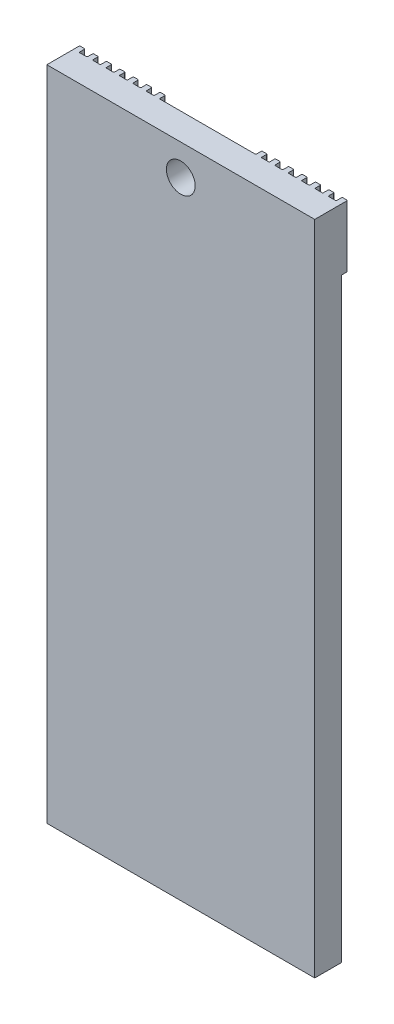
from build123d import *

# Parameters (mm, degrees)
RESSALTO_EXTRUS_O2_DEPTH = 9.2
ESBO_O5_R                = 2.15
CORTE_EXTRUS_O2_DEPTH    = 9.2
CHANFRO2_SIZE            = 0.3
SKETCH1_W                = 40
SKETCH1_H                = 3.972261678
BOSS_EXTRUDE1_DEPTH      = 88.9


with BuildPart() as part:
    # Esboço4 → Ressalto-extrusão2 (new body)
    with BuildSketch(Plane(origin=(0, 0, 0), x_dir=(1, 0, 0), z_dir=(0, 1, 0))):
        with BuildLine():
            Line((-19.2, 2.35), (-19.2, 1.65))
            ThreePointArc((-19.2, 1.65), (-19.170710678, 1.579289322), (-19.1, 1.55))
            Line((-19.1, 1.55), (-18.1, 1.55))
            ThreePointArc((-18.1, 1.55), (-18.029289322, 1.579289322), (-18, 1.65))
            Line((-18, 1.65), (-18, 2.35))
            ThreePointArc((-18, 2.35), (-17.970710678, 2.420710678), (-17.9, 2.45))
            Line((-17.9, 2.45), (-17.3, 2.45))
            ThreePointArc((-17.3, 2.45), (-17.229289322, 2.420710678), (-17.2, 2.35))
            Line((-17.2, 2.35), (-17.2, 1.65))
            ThreePointArc((-17.2, 1.65), (-17.170710678, 1.579289322), (-17.1, 1.55))
            Line((-17.1, 1.55), (-16.1, 1.55))
            ThreePointArc((-16.1, 1.55), (-16.029289322, 1.579289322), (-16, 1.65))
            Line((-16, 1.65), (-16, 2.35))
            ThreePointArc((-16, 2.35), (-15.970710678, 2.420710678), (-15.9, 2.45))
            Line((-15.9, 2.45), (-15.3, 2.45))
            ThreePointArc((-15.3, 2.45), (-15.229289322, 2.420710678), (-15.2, 2.35))
            Line((-15.2, 2.35), (-15.2, 1.65))
            ThreePointArc((-15.2, 1.65), (-15.170710678, 1.579289322), (-15.1, 1.55))
            Line((-15.1, 1.55), (-14.1, 1.55))
            ThreePointArc((-14.1, 1.55), (-14.029289322, 1.579289322), (-14, 1.65))
            Line((-14, 1.65), (-14, 2.35))
            ThreePointArc((-14, 2.35), (-13.970710678, 2.420710678), (-13.9, 2.45))
            Line((-13.9, 2.45), (-13.3, 2.45))
            ThreePointArc((-13.3, 2.45), (-13.229289322, 2.420710678), (-13.2, 2.35))
            Line((-13.2, 2.35), (-13.2, 1.65))
            ThreePointArc((-13.2, 1.65), (-13.170710678, 1.579289322), (-13.1, 1.55))
            Line((-13.1, 1.55), (-12.1, 1.55))
            ThreePointArc((-12.1, 1.55), (-12.029289322, 1.579289322), (-12, 1.65))
            Line((-12, 1.65), (-12, 2.35))
            ThreePointArc((-12, 2.35), (-11.970710678, 2.420710678), (-11.9, 2.45))
            Line((-11.9, 2.45), (-11.3, 2.45))
            ThreePointArc((-11.3, 2.45), (-11.229289322, 2.420710678), (-11.2, 2.35))
            Line((-11.2, 2.35), (-11.2, 1.65))
            ThreePointArc((-11.2, 1.65), (-11.170710678, 1.579289322), (-11.1, 1.55))
            Line((-11.1, 1.55), (-10.1, 1.55))
            ThreePointArc((-10.1, 1.55), (-10.029289322, 1.579289322), (-10, 1.65))
            Line((-10, 1.65), (-10, 2.35))
            ThreePointArc((-10, 2.35), (-9.970710678, 2.420710678), (-9.9, 2.45))
            Line((-9.9, 2.45), (-9.3, 2.45))
            ThreePointArc((-9.3, 2.45), (-9.229289322, 2.420710678), (-9.2, 2.35))
            Line((-9.2, 2.35), (-9.2, 1.65))
            ThreePointArc((-9.2, 1.65), (-9.170710678, 1.579289322), (-9.1, 1.55))
            Line((-9.1, 1.55), (-8.1, 1.55))
            ThreePointArc((-8.1, 1.55), (-8.029289322, 1.579289322), (-8, 1.65))
            Line((-8, 1.65), (-8, 2.35))
            ThreePointArc((-8, 2.35), (-7.970710678, 2.420710678), (-7.9, 2.45))
            Line((-7.9, 2.45), (-7.3, 2.45))
            ThreePointArc((-7.3, 2.45), (-7.229289322, 2.420710678), (-7.2, 2.35))
            Line((-7.2, 2.35), (-7.2, 1.65))
            ThreePointArc((-7.2, 1.65), (-7.170710678, 1.579289322), (-7.1, 1.55))
            Line((-7.1, 1.55), (7.1, 1.55))
            ThreePointArc((7.1, 1.55), (7.170710678, 1.579289322), (7.2, 1.65))
            Line((7.2, 1.65), (7.2, 2.35))
            ThreePointArc((7.2, 2.35), (7.229289322, 2.420710678), (7.3, 2.45))
            Line((7.3, 2.45), (7.9, 2.45))
            ThreePointArc((7.9, 2.45), (7.970710678, 2.420710678), (8, 2.35))
            Line((8, 2.35), (8, 1.65))
            ThreePointArc((8, 1.65), (8.029289322, 1.579289322), (8.1, 1.55))
            Line((8.1, 1.55), (9.1, 1.55))
            ThreePointArc((9.1, 1.55), (9.170710678, 1.579289322), (9.2, 1.65))
            Line((9.2, 1.65), (9.2, 2.35))
            ThreePointArc((9.2, 2.35), (9.229289322, 2.420710678), (9.3, 2.45))
            Line((9.3, 2.45), (9.9, 2.45))
            ThreePointArc((9.9, 2.45), (9.970710678, 2.420710678), (10, 2.35))
            Line((10, 2.35), (10, 1.65))
            ThreePointArc((10, 1.65), (10.029289322, 1.579289322), (10.1, 1.55))
            Line((10.1, 1.55), (11.1, 1.55))
            ThreePointArc((11.1, 1.55), (11.170710678, 1.579289322), (11.2, 1.65))
            Line((11.2, 1.65), (11.2, 2.35))
            ThreePointArc((11.2, 2.35), (11.229289322, 2.420710678), (11.3, 2.45))
            Line((11.3, 2.45), (11.9, 2.45))
            ThreePointArc((11.9, 2.45), (11.970710678, 2.420710678), (12, 2.35))
            Line((12, 2.35), (12, 1.65))
            ThreePointArc((12, 1.65), (12.029289322, 1.579289322), (12.1, 1.55))
            Line((12.1, 1.55), (13.1, 1.55))
            ThreePointArc((13.1, 1.55), (13.170710678, 1.579289322), (13.2, 1.65))
            Line((13.2, 1.65), (13.2, 2.35))
            ThreePointArc((13.2, 2.35), (13.229289322, 2.420710678), (13.3, 2.45))
            Line((13.3, 2.45), (13.9, 2.45))
            ThreePointArc((13.9, 2.45), (13.970710678, 2.420710678), (14, 2.35))
            Line((14, 2.35), (14, 1.65))
            ThreePointArc((14, 1.65), (14.029289322, 1.579289322), (14.1, 1.55))
            Line((14.1, 1.55), (15.1, 1.55))
            ThreePointArc((15.1, 1.55), (15.170710678, 1.579289322), (15.2, 1.65))
            Line((15.2, 1.65), (15.2, 2.35))
            ThreePointArc((15.2, 2.35), (15.229289322, 2.420710678), (15.3, 2.45))
            Line((15.3, 2.45), (15.9, 2.45))
            ThreePointArc((15.9, 2.45), (15.970710678, 2.420710678), (16, 2.35))
            Line((16, 2.35), (16, 1.65))
            ThreePointArc((16, 1.65), (16.029289322, 1.579289322), (16.1, 1.55))
            Line((16.1, 1.55), (17.1, 1.55))
            ThreePointArc((17.1, 1.55), (17.170710678, 1.579289322), (17.2, 1.65))
            Line((17.2, 1.65), (17.2, 2.35))
            ThreePointArc((17.2, 2.35), (17.229289322, 2.420710678), (17.3, 2.45))
            Line((17.3, 2.45), (17.9, 2.45))
            ThreePointArc((17.9, 2.45), (17.970710678, 2.420710678), (18, 2.35))
            Line((18, 2.35), (18, 1.65))
            ThreePointArc((18, 1.65), (18.029289322, 1.579289322), (18.1, 1.55))
            Line((18.1, 1.55), (19.1, 1.55))
            ThreePointArc((19.1, 1.55), (19.170710678, 1.579289322), (19.2, 1.65))
            Line((19.2, 1.65), (19.2, 2.35))
            ThreePointArc((19.2, 2.35), (19.229289322, 2.420710678), (19.3, 2.45))
            Line((19.3, 2.45), (19.9, 2.45))
            ThreePointArc((19.9, 2.45), (19.970710678, 2.420710678), (20, 2.35))
            Line((20, 2.35), (20, -2.45))
            Line((20, -2.45), (-20, -2.45))
            Line((-20, -2.45), (-20, 2.35))
            ThreePointArc((-20, 2.35), (-19.970710678, 2.420710678), (-19.9, 2.45))
            Line((-19.9, 2.45), (-19.3, 2.45))
            ThreePointArc((-19.3, 2.45), (-19.229289322, 2.420710678), (-19.2, 2.35))
        make_face()
    extrude(amount=RESSALTO_EXTRUS_O2_DEPTH)

    # Esboço5 → Corte-extrusão2 (cut)
    with BuildSketch(Plane(origin=(0, 0, -1.55), x_dir=(-1, 0, 0), z_dir=(0, 0, -1))):
        with Locations((0, 4.6)):
            Circle(ESBO_O5_R)
    extrude(amount=-CORTE_EXTRUS_O2_DEPTH, mode=Mode.SUBTRACT)

    # Chanfro2
    chanfro2_edges = [part.edges().sort_by_distance(p)[0] for p in [
        (2.15, 4.6, -1.55),
    ]]
    chamfer(chanfro2_edges, length=CHANFRO2_SIZE)

    # Sketch1 → Boss-Extrude1 (add)
    with BuildSketch(Plane.XZ):
        with Locations((0, 0.463869161)):
            Rectangle(SKETCH1_W, SKETCH1_H)
    extrude(amount=BOSS_EXTRUDE1_DEPTH)


solid = part.part
